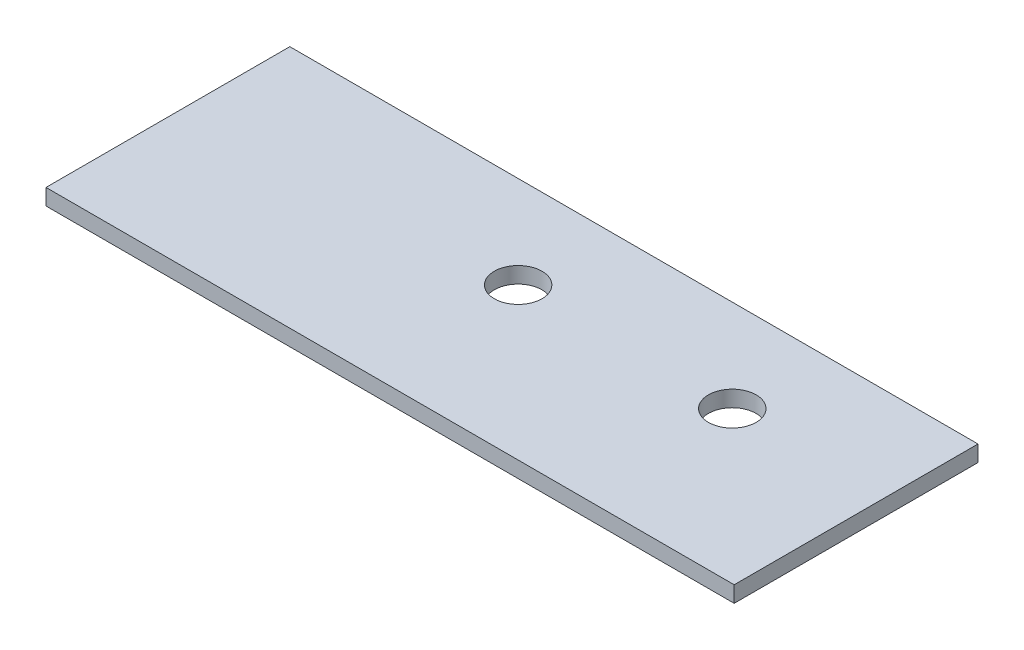
from build123d import *

# Parameters (mm, degrees)
SKETCH1_W           = 32.46
SKETCH1_H           = 11.5
SKETCH1_R           = 1.125
BOSS_EXTRUDE1_DEPTH = 0.38


with BuildPart() as part:
    # Sketch1 → Boss-Extrude1 (new body, symmetric)
    with BuildSketch(Plane(origin=(0, 0, 0), x_dir=(1, 0, 0), z_dir=(0, 1, 0))):
        Rectangle(SKETCH1_W, SKETCH1_H)
        with Locations(Location((-1.11, 1.4, 0), (0, 0, 270))):  # turned: the seam where the file's is
            Circle(SKETCH1_R, mode=Mode.SUBTRACT)
        with Locations(Location((8.99, 1.4, 0), (0, 0, 270))):  # turned: the seam where the file's is
            Circle(SKETCH1_R, mode=Mode.SUBTRACT)
    extrude(amount=BOSS_EXTRUDE1_DEPTH, both=True)


solid = part.part
